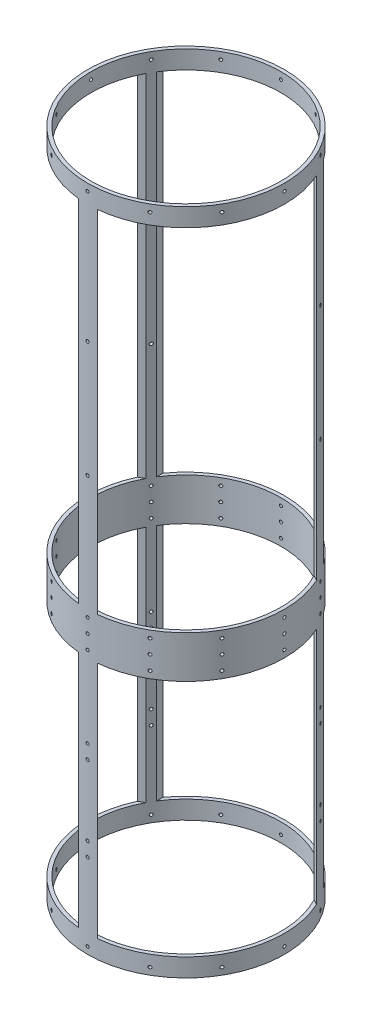
from build123d import *

# Parameters (mm, degrees)
SKETCH1_R                = 88.9
SKETCH1_R_2              = 85.725
BOSS_EXTRUDE1_DEPTH      = 301.625
CUT_EXTRUDE1_START       = -88.9
SKETCH2_W                = 144.78
SKETCH2_H                = 215.392
SKETCH2_H_2              = 316.738
CUT_EXTRUDE1_DEPTH       = 42.981991
CIRPATTERN1_COUNT        = 3
SKETCH3_R                = 1.35255
CUT_EXTRUDE2_DEPTH       = 25.908
CIRPATTERN2_COUNT        = 12
MIRROR1_COPY_1_SKETCH_R  = 1.35255
MIRROR1_COPY_1_DEPTH     = 25.908
MIRROR1_COPY_2_SKETCH_R  = 1.35255
MIRROR1_COPY_2_DEPTH     = 25.908
MIRROR1_COPY_3_SKETCH_R  = 1.35255
MIRROR1_COPY_3_DEPTH     = 25.908
MIRROR1_COPY_4_SKETCH_R  = 1.35255
MIRROR1_COPY_4_DEPTH     = 25.908
MIRROR1_COPY_5_SKETCH_R  = 1.35255
MIRROR1_COPY_5_DEPTH     = 25.908
MIRROR1_COPY_6_SKETCH_R  = 1.35255
MIRROR1_COPY_6_DEPTH     = 25.908
MIRROR1_COPY_7_SKETCH_R  = 1.35255
MIRROR1_COPY_7_DEPTH     = 25.908
MIRROR1_COPY_8_SKETCH_R  = 1.35255
MIRROR1_COPY_8_DEPTH     = 25.908
MIRROR1_COPY_9_SKETCH_R  = 1.35255
MIRROR1_COPY_9_DEPTH     = 25.908
MIRROR1_COPY_10_SKETCH_R = 1.35255
MIRROR1_COPY_10_DEPTH    = 25.908
MIRROR1_COPY_11_SKETCH_R = 1.35255
MIRROR1_COPY_11_DEPTH    = 25.908
SKETCH4_R                = 1.35255
CUT_EXTRUDE3_DEPTH       = 34.798
CIRPATTERN3_COUNT        = 3
SKETCH5_R                = 1.35255
SKETCH5_R_2              = 1.4351
CUT_EXTRUDE4_DEPTH       = 87.63
CIRPATTERN4_COUNT        = 12


with BuildPart() as part:
    # Sketch1 → Boss-Extrude1 (new body, symmetric)
    with BuildSketch(Plane(origin=(0, 0, 0), x_dir=(1, 0, 0), z_dir=(0, 1, 0))):
        Circle(SKETCH1_R)
        Circle(SKETCH1_R_2, mode=Mode.SUBTRACT)
    extrude(amount=BOSS_EXTRUDE1_DEPTH, both=True)

    # Sketch2 → Cut-Extrude1 (cut)
    with BuildSketch(Plane.XY.offset(CUT_EXTRUDE1_START)):
        with Locations((0, -177.419)):
            Rectangle(SKETCH2_W, SKETCH2_H)
        with Locations((0, 126.746)):
            Rectangle(SKETCH2_W, SKETCH2_H_2)
    cut_extrude1 = extrude(amount=CUT_EXTRUDE1_DEPTH, mode=Mode.SUBTRACT)

    # CirPattern1: Cut-Extrude1 ×3 about axis
    cirpattern1_axis = Axis((0, 0, 0), (0, 1, 0))
    for i in range(1, CIRPATTERN1_COUNT):
        add(cut_extrude1.rotate(cirpattern1_axis, i * 360 / CIRPATTERN1_COUNT), mode=Mode.SUBTRACT)

    # Sketch3 → Cut-Extrude2 (cut)
    with BuildSketch(Plane.XY.offset(88.9)):
        with Locations((0, 295.275)):
            Circle(SKETCH3_R)
    cut_extrude2 = extrude(amount=-CUT_EXTRUDE2_DEPTH, mode=Mode.SUBTRACT)

    # CirPattern2: Cut-Extrude2 ×12 about axis
    cirpattern2_axis = Axis((0, 301.625, 0), (0, -1, 0))
    for i in range(1, CIRPATTERN2_COUNT):
        add(cut_extrude2.rotate(cirpattern2_axis, i * 360 / CIRPATTERN2_COUNT), mode=Mode.SUBTRACT)

    # Mirror1: Cut-Extrude2 across plane
    add(cut_extrude2.mirror(Plane.ZX), mode=Mode.SUBTRACT)

    # Mirror1 copy 1 sketch → Mirror1 copy 1 (cut)
    with BuildSketch(Plane(origin=(-44.45, 0, 76.989658396), x_dir=(0.866025404, 0, 0.5), z_dir=(-0.5, 0, 0.866025404))):
        with Locations((0, -295.275)):
            Circle(MIRROR1_COPY_1_SKETCH_R)
    extrude(amount=-MIRROR1_COPY_1_DEPTH, mode=Mode.SUBTRACT)

    # Mirror1 copy 2 sketch → Mirror1 copy 2 (cut)
    with BuildSketch(Plane(origin=(-76.989658396, 0, 44.45), x_dir=(0.5, 0, 0.866025404), z_dir=(-0.866025404, 0, 0.5))):
        with Locations((0, -295.275)):
            Circle(MIRROR1_COPY_2_SKETCH_R)
    extrude(amount=-MIRROR1_COPY_2_DEPTH, mode=Mode.SUBTRACT)

    # Mirror1 copy 3 sketch → Mirror1 copy 3 (cut)
    with BuildSketch(Plane.ZY.offset(88.9)):
        with Locations((0, -295.275)):
            Circle(MIRROR1_COPY_3_SKETCH_R)
    extrude(amount=-MIRROR1_COPY_3_DEPTH, mode=Mode.SUBTRACT)

    # Mirror1 copy 4 sketch → Mirror1 copy 4 (cut)
    with BuildSketch(Plane(origin=(-76.989658396, 0, -44.45), x_dir=(-0.5, 0, 0.866025404), z_dir=(-0.866025404, 0, -0.5))):
        with Locations((0, -295.275)):
            Circle(MIRROR1_COPY_4_SKETCH_R)
    extrude(amount=-MIRROR1_COPY_4_DEPTH, mode=Mode.SUBTRACT)

    # Mirror1 copy 5 sketch → Mirror1 copy 5 (cut)
    with BuildSketch(Plane(origin=(-44.45, 0, -76.989658396), x_dir=(-0.866025404, 0, 0.5), z_dir=(-0.5, 0, -0.866025404))):
        with Locations((0, -295.275)):
            Circle(MIRROR1_COPY_5_SKETCH_R)
    extrude(amount=-MIRROR1_COPY_5_DEPTH, mode=Mode.SUBTRACT)

    # Mirror1 copy 6 sketch → Mirror1 copy 6 (cut)
    with BuildSketch(Plane(origin=(0, 0, -88.9), x_dir=(-1, 0, 0), z_dir=(0, 0, -1))):
        with Locations((0, -295.275)):
            Circle(MIRROR1_COPY_6_SKETCH_R)
    extrude(amount=-MIRROR1_COPY_6_DEPTH, mode=Mode.SUBTRACT)

    # Mirror1 copy 7 sketch → Mirror1 copy 7 (cut)
    with BuildSketch(Plane(origin=(44.45, 0, -76.989658396), x_dir=(-0.866025404, 0, -0.5), z_dir=(0.5, 0, -0.866025404))):
        with Locations((0, -295.275)):
            Circle(MIRROR1_COPY_7_SKETCH_R)
    extrude(amount=-MIRROR1_COPY_7_DEPTH, mode=Mode.SUBTRACT)

    # Mirror1 copy 8 sketch → Mirror1 copy 8 (cut)
    with BuildSketch(Plane(origin=(76.989658396, 0, -44.45), x_dir=(-0.5, 0, -0.866025404), z_dir=(0.866025404, 0, -0.5))):
        with Locations((0, -295.275)):
            Circle(MIRROR1_COPY_8_SKETCH_R)
    extrude(amount=-MIRROR1_COPY_8_DEPTH, mode=Mode.SUBTRACT)

    # Mirror1 copy 9 sketch → Mirror1 copy 9 (cut)
    with BuildSketch(Plane(origin=(88.9, 0, 0), x_dir=(0, 0, -1), z_dir=(1, 0, 0))):
        with Locations((0, -295.275)):
            Circle(MIRROR1_COPY_9_SKETCH_R)
    extrude(amount=-MIRROR1_COPY_9_DEPTH, mode=Mode.SUBTRACT)

    # Mirror1 copy 10 sketch → Mirror1 copy 10 (cut)
    with BuildSketch(Plane(origin=(76.989658396, 0, 44.45), x_dir=(0.5, 0, -0.866025404), z_dir=(0.866025404, 0, 0.5))):
        with Locations((0, -295.275)):
            Circle(MIRROR1_COPY_10_SKETCH_R)
    extrude(amount=-MIRROR1_COPY_10_DEPTH, mode=Mode.SUBTRACT)

    # Mirror1 copy 11 sketch → Mirror1 copy 11 (cut)
    with BuildSketch(Plane(origin=(44.45, 0, 76.989658396), x_dir=(0.866025404, 0, -0.5), z_dir=(0.5, 0, 0.866025404))):
        with Locations((0, -295.275)):
            Circle(MIRROR1_COPY_11_SKETCH_R)
    extrude(amount=-MIRROR1_COPY_11_DEPTH, mode=Mode.SUBTRACT)

    # Sketch4 → Cut-Extrude3 (cut)
    with BuildSketch(Plane.XY.offset(88.9)):
        with Locations((0, -225.425)):
            Circle(SKETCH4_R)
        with Locations((0, -212.725)):
            Circle(SKETCH4_R)
        with Locations((0, -149.225)):
            Circle(SKETCH4_R)
        with Locations((0, -136.525)):
            Circle(SKETCH4_R)
    cut_extrude3 = extrude(amount=-CUT_EXTRUDE3_DEPTH, mode=Mode.SUBTRACT)

    # CirPattern3: Cut-Extrude3 ×3 about axis
    cirpattern3_axis = Axis((0, 301.625, 0), (0, -1, 0))
    for i in range(1, CIRPATTERN3_COUNT):
        add(cut_extrude3.rotate(cirpattern3_axis, i * 360 / CIRPATTERN3_COUNT), mode=Mode.SUBTRACT)

    # Sketch5 → Cut-Extrude4 (cut)
    with BuildSketch(Plane.XY.offset(88.9)):
        with Locations((0, -50.673)):
            Circle(SKETCH5_R)
        with Locations((0, 73.025)):
            Circle(SKETCH5_R_2)
        with Locations((0, 177.927)):
            Circle(SKETCH5_R_2)
        with Locations((0, -37.973)):
            Circle(SKETCH5_R)
        with Locations((0, -63.373)):
            Circle(SKETCH5_R)
    cut_extrude4 = extrude(amount=-CUT_EXTRUDE4_DEPTH, mode=Mode.SUBTRACT)

    # CirPattern4: Cut-Extrude4 ×12 about axis
    cirpattern4_axis = Axis((0, 301.625, 0), (0, -1, 0))
    for i in range(1, CIRPATTERN4_COUNT):
        add(cut_extrude4.rotate(cirpattern4_axis, i * 360 / CIRPATTERN4_COUNT), mode=Mode.SUBTRACT)


solid = part.part
